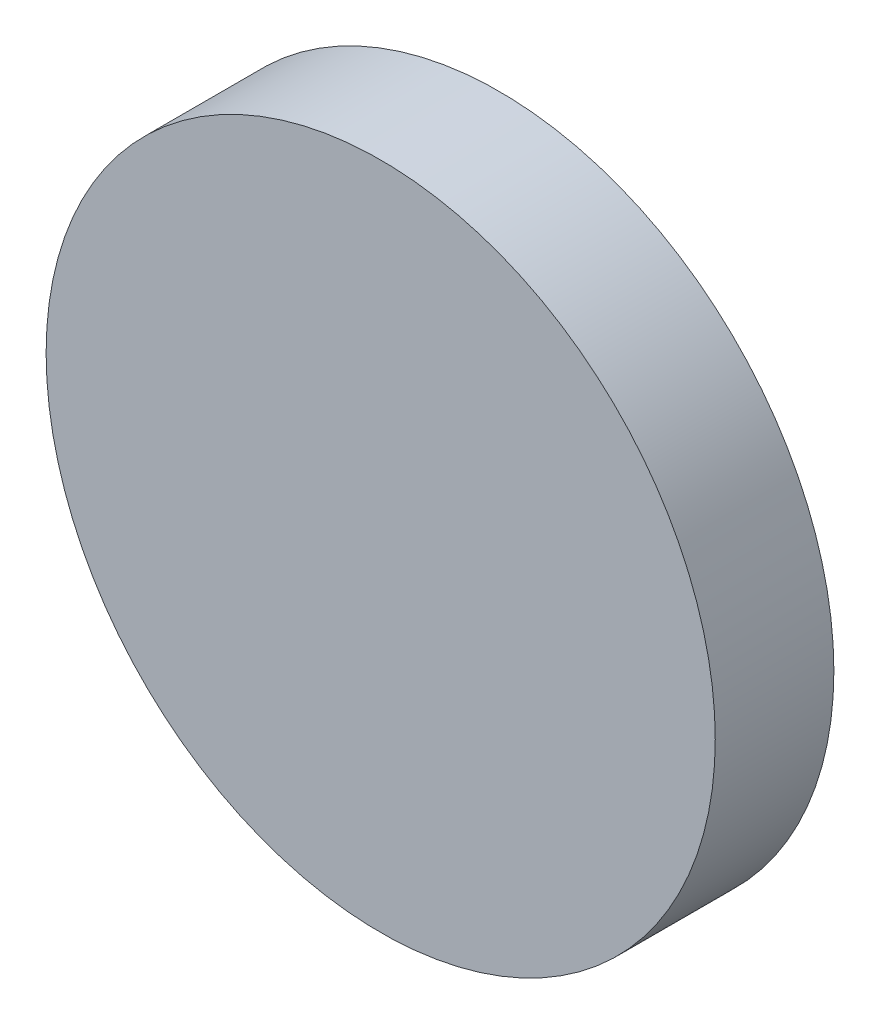
from build123d import *

# Parameters (mm, degrees)
SKETCH3_R           = 11
BOSS_EXTRUDE1_DEPTH = 3.9


with BuildPart() as part:
    # Sketch3 → Boss-Extrude1 (new body)
    with BuildSketch(Plane.XY):
        Circle(SKETCH3_R)
    extrude(amount=BOSS_EXTRUDE1_DEPTH)


solid = part.part
